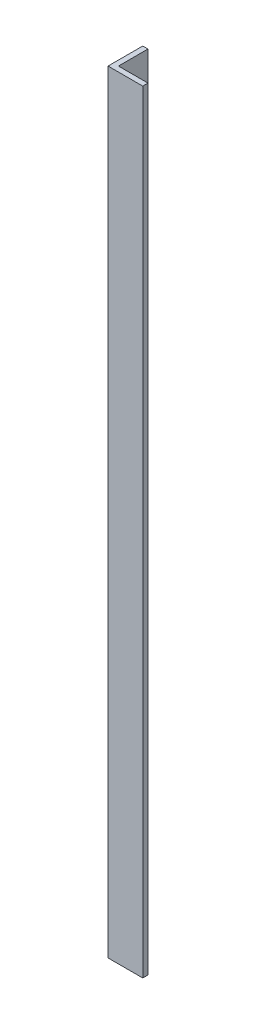
from build123d import *

# Parameters (mm, degrees)
BOSS_EXTRUDE1_DEPTH = 1130.3


with BuildPart() as part:
    # Sketch1 → Boss-Extrude1 (new body)
    with BuildSketch(Plane(origin=(0, 0, 0), x_dir=(1, 0, 0), z_dir=(0, 1, 0))):
        Polygon((0, 0), (0, 50.8), (7.62, 50.8), (7.62, 7.62), (50.8, 7.62), (50.8, 0), align=None)
    extrude(amount=BOSS_EXTRUDE1_DEPTH)


solid = part.part
